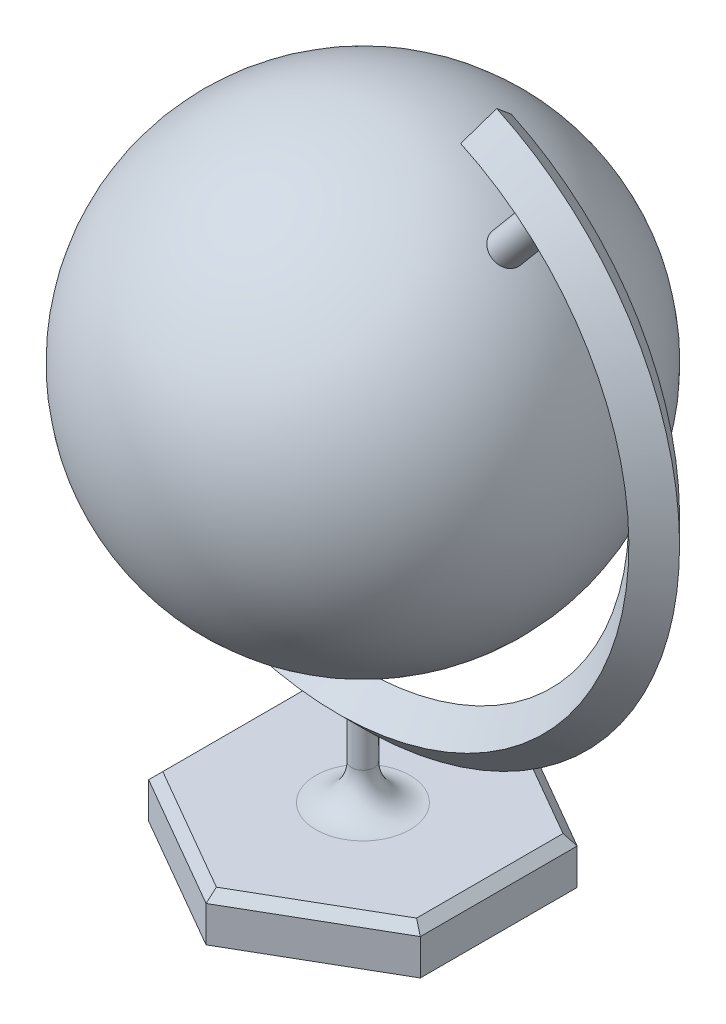
from build123d import *

# Parameters (mm, degrees)
BOSS_EXTRUDE1_DEPTH             = 10
SHELL1_T                        = -2
REVOLVE_THIN1_ANGLE             = 55
REVOLVE_THIN1_OTHER_WAY_ANGLE   = 155
BOSS_EXTRUDE2_REACH             = 157.311
SKETCH5_R                       = 3.5
BOSS_EXTRUDE2_DIRECTION_2_REACH = 157.311
BOSS_EXTRUDE3_REACH             = 174.35
SKETCH6_R                       = 2.5
FILLET1_R                       = 8
CHAMFER1_SIZE                   = 2


with BuildPart() as part:
    # Sketch1 → Boss-Extrude1 (new body)
    with BuildSketch(Plane(origin=(0, 0, 0), x_dir=(1, 0, 0), z_dir=(0, 1, 0))):
        Polygon((0, 35), (-30.310889132, 17.5), (-30.310889132, -17.5), (0, -35), (30.310889132, -17.5), (30.310889132, 17.5), align=None)
    extrude(amount=BOSS_EXTRUDE1_DEPTH)

    # Shell1
    shell1_openings = [part.faces().sort_by_distance(p)[0] for p in [
        (0, 0, 0),
    ]]
    offset(amount=SHELL1_T, openings=shell1_openings, kind=Kind.INTERSECTION)


with BuildPart() as body_2:
    # Sketch2 → Revolve1 (revolve)
    with BuildSketch(Plane.XY):
        with BuildLine():
            Line((0, 145), (0, 45))
            ThreePointArc((0, 45), (50, 95), (0, 145))
        make_face()
    revolve(axis=Axis((0, 145, 0), (0, -1, 0)))


with BuildPart() as body_3:
    # Sketch4 → Revolve-Thin1 (revolve)
    with BuildSketch(Plane(origin=(0, 0, 0), x_dir=(0, 0, -1), z_dir=(1, 0, 0))):
        Polygon((0, 24.343145751), (-5.656854249, 30), (0, 35.656854249), (5.656854249, 30), align=None)
        Polygon((0, 25.757359313), (-4.242640687, 30), (0, 34.242640687), (4.242640687, 30), align=None, mode=Mode.SUBTRACT)
    revolve(axis=Axis((0, 95, 0), (0, 0, -1)), revolution_arc=REVOLVE_THIN1_ANGLE)

    # Sketch4 → Revolve-Thin1 other way (revolve)
    with BuildSketch(Plane(origin=(0, 0, 0), x_dir=(0, 0, -1), z_dir=(1, 0, 0))):
        Polygon((0, 24.343145751), (-5.656854249, 30), (0, 35.656854249), (5.656854249, 30), align=None)
        Polygon((0, 25.757359313), (-4.242640687, 30), (0, 34.242640687), (4.242640687, 30), align=None, mode=Mode.SUBTRACT)
    revolve(axis=Axis((0, 95, 0), (0, 0, 1)), revolution_arc=REVOLVE_THIN1_OTHER_WAY_ANGLE)

    # Sketch5 → Boss-Extrude2 (add, up to next)
    with BuildSketch(Plane(origin=(46.778368268, 55.748288439, 0), x_dir=(0, 0, 1), z_dir=(0.6427876096865406, 0.7660444431189771, 0)), mode=Mode.PRIVATE) as boss_extrude2_sk1:
        with Locations(Location((0, -61.06482292, 0), (0, 0, 89.999995384))):
            Circle(SKETCH5_R)
    boss_extrude2_tool1 = extrude(boss_extrude2_sk1.sketch, amount=BOSS_EXTRUDE2_REACH, mode=Mode.PRIVATE) - body_3.part

    add(body_2.part)  # Boss-Extrude2 merges body 2
    add(boss_extrude2_tool1.solids().sort_by_distance((0, 95, 0))[0])

    # Sketch5 → Boss-Extrude2 direction 2 (add, up to next)
    with BuildSketch(Plane(origin=(46.778368268, 55.748288439, 0), x_dir=(0, 0, 1), z_dir=(0.6427876096865406, 0.7660444431189771, 0)), mode=Mode.PRIVATE) as boss_extrude2_direction_2_sk1:
        with Locations(Location((0, -61.06482292, 0), (0, 0, 89.999995384))):
            Circle(SKETCH5_R)
    boss_extrude2_direction_2_tool1 = extrude(boss_extrude2_direction_2_sk1.sketch, amount=-BOSS_EXTRUDE2_DIRECTION_2_REACH, mode=Mode.PRIVATE) - body_3.part
    add(boss_extrude2_direction_2_tool1.solids().sort_by_distance((0, 95, 0))[0])

    # Sketch6 → Boss-Extrude3 (add, up to next)
    with BuildSketch(Plane(origin=(0, 10, 0), x_dir=(1, 0, 0), z_dir=(0, 1, 0)), mode=Mode.PRIVATE) as boss_extrude3_sk1:
        with Locations(Location((0, 0, 0), (0, 0, 179.999998803))):
            Circle(SKETCH6_R)
    boss_extrude3_tool1 = extrude(boss_extrude3_sk1.sketch, amount=BOSS_EXTRUDE3_REACH, mode=Mode.PRIVATE) - body_3.part

    add(part.part)  # Boss-Extrude3 merges part
    add(boss_extrude3_tool1.solids().sort_by_distance((0, 10, 0))[0])

    # Fillet1
    fillet1_edges = [body_3.edges().sort_by_distance(p)[0] for p in [
        (2.5, 10, 5.2e-08),
    ]]
    fillet(fillet1_edges, radius=FILLET1_R)

    # Chamfer1
    chamfer1_edges = [body_3.edges().sort_by_distance(p)[0] for p in [
        (-30.310889132, 10, 0),
        (-15.155444566, 10, 26.25),
        (15.155444566, 10, 26.25),
        (30.310889132, 10, 0),
        (15.155444566, 10, -26.25),
        (-15.155444566, 10, -26.25),
    ]]
    chamfer(chamfer1_edges, length=CHAMFER1_SIZE)


solid = body_3.part
